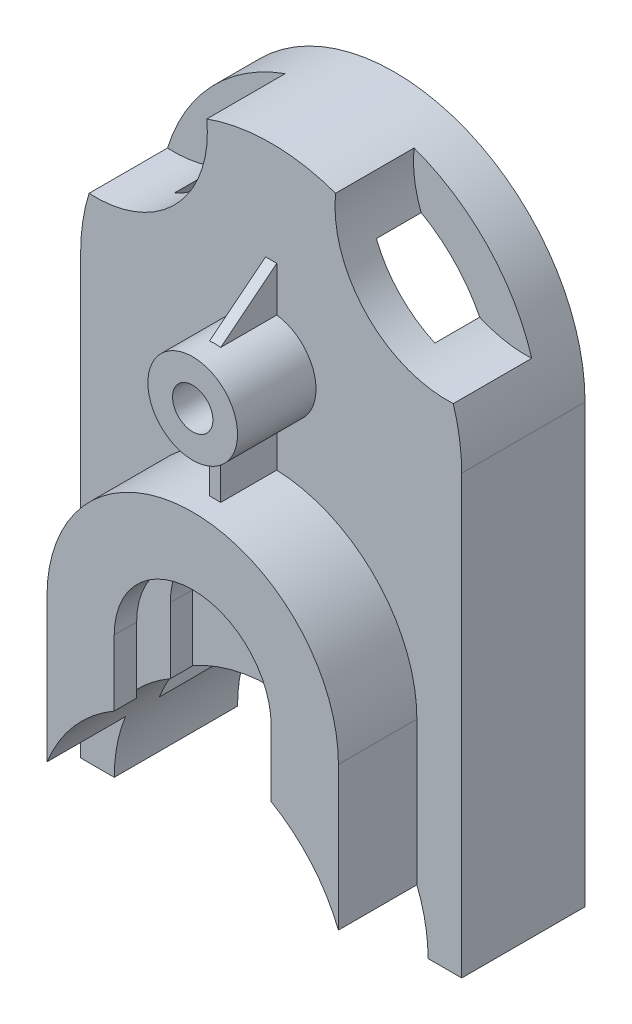
from build123d import *

# Parameters (mm, degrees)
SKETCH1_W           = 170
SKETCH1_H           = 280
BOSS_EXTRUDE1_DEPTH = 90
CUT_EXTRUDE1_DEPTH  = 90
CUT_EXTRUDE2_DEPTH  = 90
SKETCH4_W           = 20
SKETCH4_H           = 35
CUT_EXTRUDE3_DEPTH  = 299
CUT_EXTRUDE4_DEPTH  = 40
SKETCH6_R           = 9
CUT_EXTRUDE5_DEPTH  = 50
CUT_EXTRUDE6_DEPTH  = 35
SKETCH8_R           = 9
CUT_EXTRUDE7_DEPTH  = 35
CUT_EXTRUDE9_DEPTH  = 15
SKETCH10_R          = 20
BOSS_EXTRUDE2_DEPTH = 35
SKETCH11_R          = 9
CUT_EXTRUDE10_DEPTH = 35
SKETCH12_W          = 5
SKETCH12_H          = 20
SKETCH12_H_2        = 20.204959883
BOSS_EXTRUDE3_DEPTH = 25
CUT_EXTRUDE11_DEPTH = 35
CUT_EXTRUDE12_DEPTH = 10


with BuildPart() as part:
    # Sketch1 → Boss-Extrude1 (new body)
    with BuildSketch(Plane.XY):
        with Locations((85, 140)):
            Rectangle(SKETCH1_W, SKETCH1_H)
    extrude(amount=BOSS_EXTRUDE1_DEPTH)

    # Sketch2 → Cut-Extrude1 (cut)
    with BuildSketch(Plane.XY.offset(90)):
        with BuildLine():
            Line((0, 280), (0, 195))
            ThreePointArc((0, 195), (24.895923599, 255.104076401), (85, 280))
            Line((85, 280), (0, 280))
        make_face()
        with BuildLine():
            Line((170, 280), (85, 280))
            ThreePointArc((85, 280), (145.104076401, 255.104076401), (170, 195))
            Line((170, 195), (170, 280))
        make_face()
    extrude(amount=-CUT_EXTRUDE1_DEPTH, mode=Mode.SUBTRACT)

    # Sketch3 → Cut-Extrude2 (cut)
    with BuildSketch(Plane.XY.offset(90)):
        with BuildLine():
            Line((15, 0), (155, 0))
            ThreePointArc((155, 0), (85, 70), (15, 0))
        make_face()
    extrude(amount=-CUT_EXTRUDE2_DEPTH, mode=Mode.SUBTRACT)

    # Sketch4 → Cut-Extrude3 (cut)
    with BuildSketch(Plane(origin=(0, 0, 0), x_dir=(1, 0, 0), z_dir=(0, 1, 0))):
        with Locations((10, -72.5)):
            Rectangle(SKETCH4_W, SKETCH4_H)
        with Locations((160, -72.5)):
            Rectangle(SKETCH4_W, SKETCH4_H)
    extrude(amount=CUT_EXTRUDE3_DEPTH, mode=Mode.SUBTRACT)

    # Sketch5 → Cut-Extrude4 (cut)
    with BuildSketch(Plane(origin=(0, 0, 0), x_dir=(-1, 0, 0), z_dir=(0, 0, -1))):
        with BuildLine():
            Line((-20, 25.980762114), (-20, 195))
            ThreePointArc((-20, 195), (-85, 260), (-150, 195))
            Line((-150, 195), (-150, 25.980762114))
            ThreePointArc((-150, 25.980762114), (-85, 70), (-20, 25.980762114))
        make_face()
    extrude(amount=-CUT_EXTRUDE4_DEPTH, mode=Mode.SUBTRACT)

    # Sketch6 → Cut-Extrude5 (cut)
    with BuildSketch(Plane.XY.offset(90)):
        with Locations((85, 90)):
            Circle(SKETCH6_R)
    extrude(amount=-CUT_EXTRUDE5_DEPTH, mode=Mode.SUBTRACT)

    # Sketch7 → Cut-Extrude6 (cut)
    with BuildSketch(Plane.XY.offset(90)):
        with BuildLine():
            Line((20, 90), (20, 249.772255751))
            ThreePointArc((20, 249.772255751), (85, 280), (150, 249.772255751))
            Line((150, 249.772255751), (150, 90))
            ThreePointArc((150, 90), (85, 155), (20, 90))
        make_face()
    extrude(amount=-CUT_EXTRUDE6_DEPTH, mode=Mode.SUBTRACT)

    # Sketch8 → Cut-Extrude7 (cut)
    with BuildSketch(Plane.XY.offset(90)):
        with BuildLine():
            ThreePointArc((120, 90), (85, 125), (50, 90))
            Line((50, 90), (50, 60.621778265))
            ThreePointArc((50, 60.621778265), (85, 70), (120, 60.621778265))
            Line((120, 60.621778265), (120, 90))
        make_face()
        with Locations((85, 90)):
            Circle(SKETCH8_R, mode=Mode.SUBTRACT)
    extrude(amount=-CUT_EXTRUDE7_DEPTH, mode=Mode.SUBTRACT)

    # Sketch9 → Cut-Extrude9 (cut)
    with BuildSketch(Plane.XY.offset(80)):
        with BuildLine():
            Line((35, 90), (50, 90))
            ThreePointArc((50, 90), (85, 125), (120, 90))
            Line((120, 90), (135, 90))
            ThreePointArc((135, 90), (85, 140), (35, 90))
        make_face()
        with BuildLine():
            Line((50, 90), (35, 90))
            Line((35, 90), (35, 48.989794856))
            ThreePointArc((35, 48.989794856), (85, 70), (135, 48.989794856))
            Line((135, 48.989794856), (135, 90))
            Line((135, 90), (120, 90))
            ThreePointArc((120, 90), (85, 125), (50, 90))
        make_face()
    extrude(amount=-CUT_EXTRUDE9_DEPTH, mode=Mode.SUBTRACT)

    # Sketch10 → Boss-Extrude2 (add)
    with BuildSketch(Plane.XY.offset(55)):
        with Locations((85, 195)):
            Circle(SKETCH10_R)
    extrude(amount=BOSS_EXTRUDE2_DEPTH)

    # Sketch11 → Cut-Extrude10 (cut)
    with BuildSketch(Plane.XY.offset(90)):
        with Locations((85, 195)):
            Circle(SKETCH11_R)
    extrude(amount=-CUT_EXTRUDE10_DEPTH, mode=Mode.SUBTRACT)

    # Sketch12 → Boss-Extrude3 (add)
    with BuildSketch(Plane.XY.offset(55)):
        with Locations((85, 224.843134833)):
            Rectangle(SKETCH12_W, SKETCH12_H)
        with Locations((85, 165.054385226)):
            Rectangle(SKETCH12_W, SKETCH12_H_2)
    extrude(amount=BOSS_EXTRUDE3_DEPTH)

    # Sketch13 → Cut-Extrude11 (cut)
    with BuildSketch(Plane.XY.offset(55)):
        with BuildLine():
            ThreePointArc((3.759615954, 220), (42.697632957, 235.393046487), (56.277186767, 275))
            ThreePointArc((56.277186767, 275), (23.524588745, 253.700713889), (3.759615954, 220))
        make_face()
        with BuildLine():
            ThreePointArc((166.240384046, 220), (146.475411255, 253.700713889), (113.722813233, 275))
            ThreePointArc((113.722813233, 275), (127.302367043, 235.393046487), (166.240384046, 220))
        make_face()
    extrude(amount=-CUT_EXTRUDE11_DEPTH, mode=Mode.SUBTRACT)

    # Sketch14 → Cut-Extrude12 (cut)
    with BuildSketch(Plane(origin=(87.5, 0, 0), x_dir=(0, 0, -1), z_dir=(1, 0, 0))):
        Polygon((-80, 214.843134833), (-55, 234.843134833), (-80, 234.843134833), align=None)
    extrude(amount=-CUT_EXTRUDE12_DEPTH, mode=Mode.SUBTRACT)


solid = part.part
